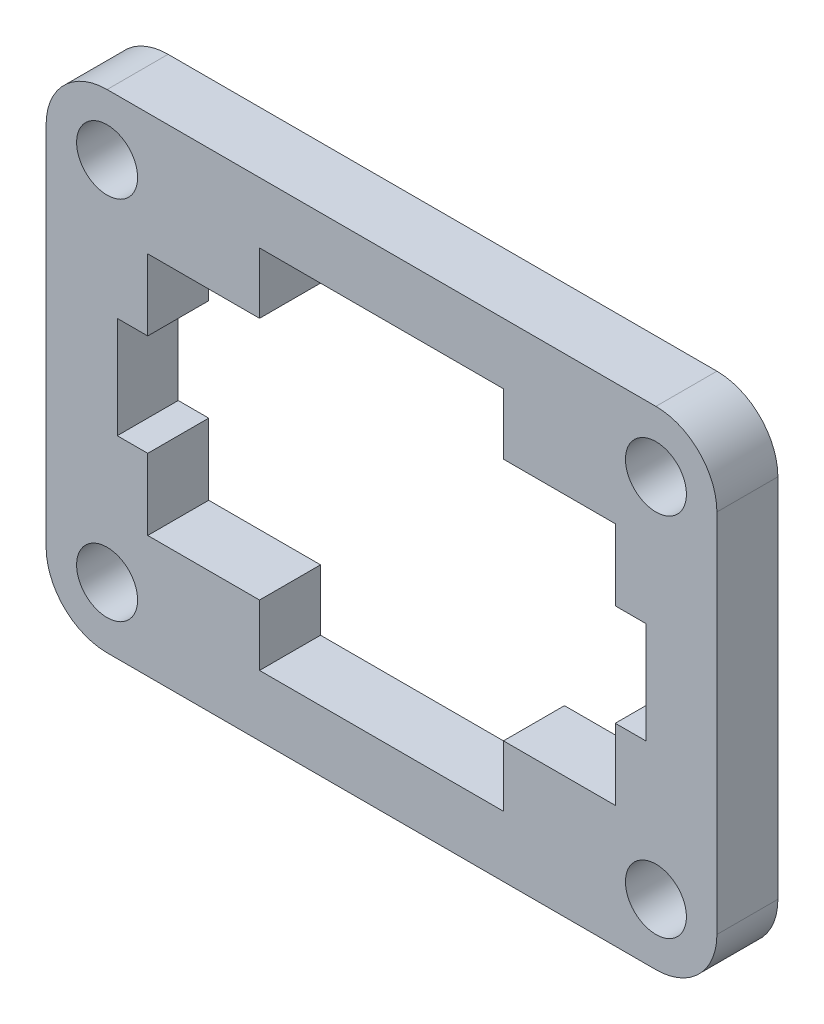
from build123d import *

# Parameters (mm, degrees)
ESQUISSE16_R        = 1.5
BOSS_EXTRU_16_DEPTH = 3


with BuildPart() as part:
    # Esquisse16 → Boss.-Extru.16 (new body)
    with BuildSketch(Plane.XY):
        with BuildLine():
            Line((27.030251009, -10.651447746), (54.030251009, -10.651447746))
            ThreePointArc((54.030251009, -10.651447746), (56.151571352, -11.530127403), (57.030251009, -13.651447746))
            Line((57.030251009, -13.651447746), (57.030251009, -31.651447746))
            ThreePointArc((57.030251009, -31.651447746), (56.151571352, -33.77276809), (54.030251009, -34.651447746))
            Line((54.030251009, -34.651447746), (27.030251009, -34.651447746))
            ThreePointArc((27.030251009, -34.651447746), (24.908930665, -33.77276809), (24.030251009, -31.651447746))
            Line((24.030251009, -31.651447746), (24.030251009, -13.651447746))
            ThreePointArc((24.030251009, -13.651447746), (24.908930665, -11.530127403), (27.030251009, -10.651447746))
        make_face()
        with Locations((27.030251009, -13.651447746)):
            Circle(ESQUISSE16_R, mode=Mode.SUBTRACT)
        with Locations((54.030251009, -13.651447746)):
            Circle(ESQUISSE16_R, mode=Mode.SUBTRACT)
        with Locations((54.030251009, -31.651447746)):
            Circle(ESQUISSE16_R, mode=Mode.SUBTRACT)
        with Locations((27.030251009, -31.651447746)):
            Circle(ESQUISSE16_R, mode=Mode.SUBTRACT)
        Polygon((29.030251009, -28.651447746), (34.530251009, -28.651447746), (34.530251009, -31.651447746), (46.530251009, -31.651447746), (46.530251009, -28.651447746), (52.030251009, -28.651447746), (52.030251009, -25.151447746), (53.530251009, -25.151447746), (53.530251009, -20.151447746), (52.030251009, -20.151447746), (52.030251009, -16.651447746), (46.530251009, -16.651447746), (46.530251009, -13.651447746), (34.530251009, -13.651447746), (34.530251009, -16.651447746), (29.030251009, -16.651447746), (29.030251009, -20.151447746), (27.530251009, -20.151447746), (27.530251009, -25.151447746), (29.030251009, -25.151447746), align=None, mode=Mode.SUBTRACT)
    extrude(amount=BOSS_EXTRU_16_DEPTH)


solid = part.part
